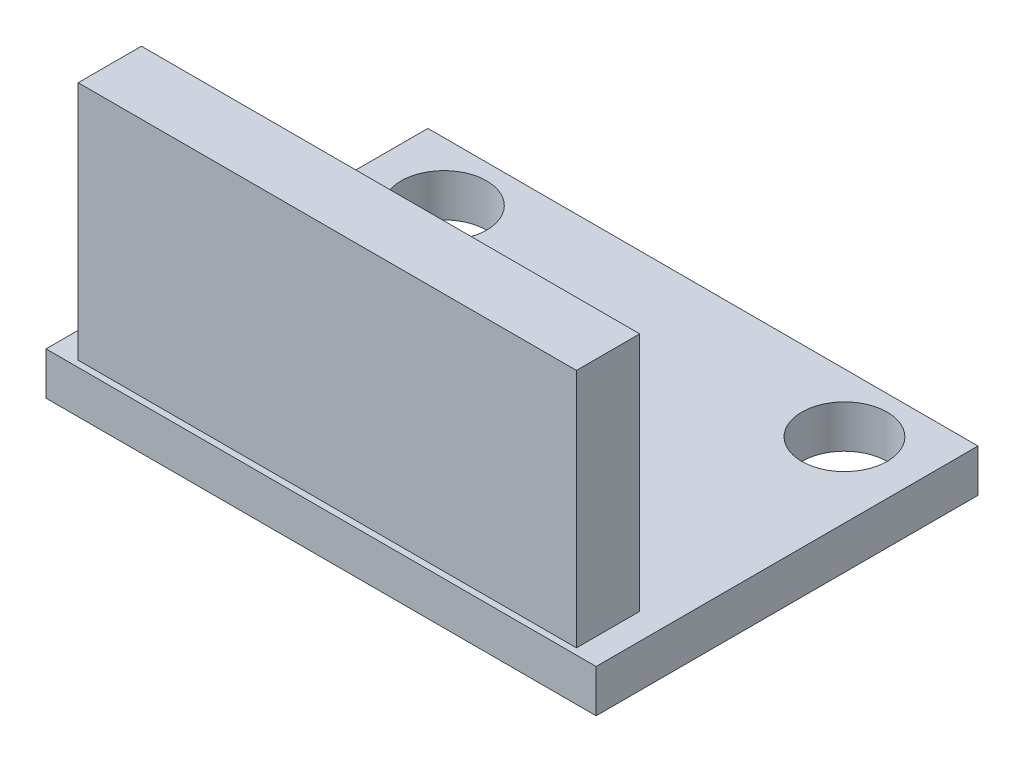
from build123d import *

# Parameters (mm, degrees)
SKETCH1_W           = 20.6
SKETCH1_H           = 14.3
SKETCH1_R           = 1.6
BOSS_EXTRUDE1_DEPTH = 1.6
SKETCH2_W           = 18.658076696
SKETCH2_H           = 2.368570216
BOSS_EXTRUDE2_DEPTH = 9


with BuildPart() as part:
    # Sketch1 → Boss-Extrude1 (new body)
    with BuildSketch(Plane(origin=(0, 0, 0), x_dir=(1, 0, 0), z_dir=(0, 1, 0))):
        Rectangle(SKETCH1_W, SKETCH1_H)
        with Locations((-7.5, 4.95)):
            Circle(SKETCH1_R, mode=Mode.SUBTRACT)
        with Locations((7.5, 4.95)):
            Circle(SKETCH1_R, mode=Mode.SUBTRACT)
    extrude(amount=BOSS_EXTRUDE1_DEPTH)

    # Sketch2 → Boss-Extrude2 (add)
    with BuildSketch(Plane(origin=(0, 1.6, 0), x_dir=(1, 0, 0), z_dir=(0, 1, 0))):
        with Locations((0, -5.731493021)):
            Rectangle(SKETCH2_W, SKETCH2_H)
    extrude(amount=BOSS_EXTRUDE2_DEPTH)


solid = part.part
